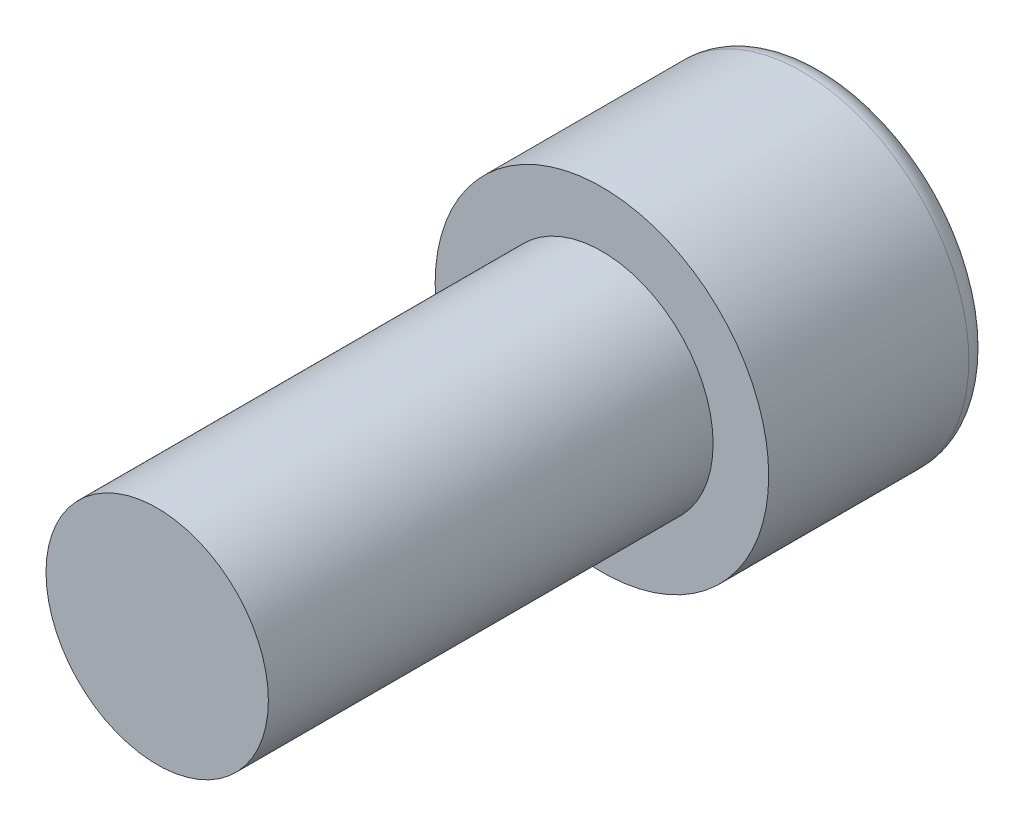
from build123d import *

# Parameters (mm, degrees)
SKETCH1_R           = 1
BOSS_EXTRUDE1_DEPTH = 4
SKETCH2_R           = 1.5
BOSS_EXTRUDE2_DEPTH = 2
FILLET1_R           = 0.2
CUT_EXTRUDE1_DEPTH  = 1.8


with BuildPart() as part:
    # Sketch1 → Boss-Extrude1 (new body)
    with BuildSketch(Plane.XY):
        Circle(SKETCH1_R)
    extrude(amount=BOSS_EXTRUDE1_DEPTH)

    # Sketch2 → Boss-Extrude2 (add)
    with BuildSketch(Plane(origin=(0, 0, 0), x_dir=(-1, 0, 0), z_dir=(0, 0, -1))):
        Circle(SKETCH2_R)
    extrude(amount=BOSS_EXTRUDE2_DEPTH)

    # Fillet1
    fillet1_edges = [part.edges().sort_by_distance(p)[0] for p in [
        (1.5, 0, -2),
    ]]
    fillet(fillet1_edges, radius=FILLET1_R)

    # Sketch3 → Cut-Extrude1 (cut)
    with BuildSketch(Plane(origin=(0, 0, -2), x_dir=(-1, 0, 0), z_dir=(0, 0, -1))):
        Polygon((0, -0.866025404), (0.75, -0.433012702), (0.75, 0.433012702), (0, 0.866025404), (-0.75, 0.433012702), (-0.75, -0.433012702), align=None)
    extrude(amount=-CUT_EXTRUDE1_DEPTH, mode=Mode.SUBTRACT)


solid = part.part
